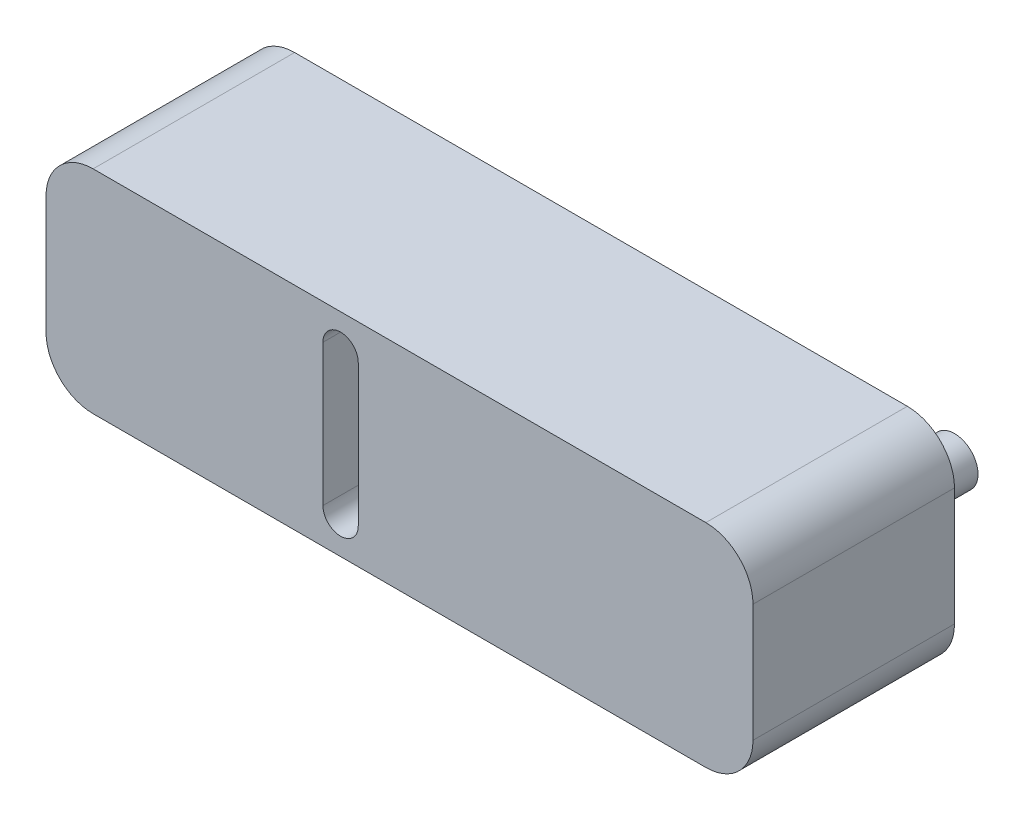
from build123d import *

# Parameters (mm, degrees)
SKETCH1_W           = 76.2
SKETCH1_H           = 22.86
BOSS_EXTRUDE1_DEPTH = 21.717
CUT_EXTRUDE3_REACH  = 23.717
FILLET1_R           = 5.08
SKETCH3_R           = 2.54
BOSS_EXTRUDE2_DEPTH = 8.89


with BuildPart() as part:
    # Sketch1 → Boss-Extrude1 (new body)
    with BuildSketch(Plane.XY):
        Rectangle(SKETCH1_W, SKETCH1_H)
    extrude(amount=-BOSS_EXTRUDE1_DEPTH)

    # Sketch2 → Cut-Extrude3 (cut, up to next)
    with BuildSketch(Plane.XY, mode=Mode.PRIVATE) as cut_extrude3_sk1:
        with BuildLine():
            Line((-8.255, -7.62), (-8.255, 7.62))
            ThreePointArc((-8.255, 7.62), (-6.35, 9.525), (-4.445, 7.62))
            Line((-4.445, 7.62), (-4.445, -7.62))
            ThreePointArc((-4.445, -7.62), (-6.35, -9.525), (-8.255, -7.62))
        make_face()
    cut_extrude3_tool1 = extrude(cut_extrude3_sk1.sketch, amount=-CUT_EXTRUDE3_REACH, mode=Mode.PRIVATE) & part.part
    add(cut_extrude3_tool1.solids().sort_by_distance((-6.35, 0, 0))[0], mode=Mode.SUBTRACT)

    # Fillet1
    fillet1_edges = [part.edges().sort_by_distance(p)[0] for p in [
        (38.1, -11.43, -10.8585),
        (-38.1, -11.43, -10.8585),
        (-38.1, 11.43, -10.8585),
        (38.1, 11.43, -10.8585),
    ]]
    fillet(fillet1_edges, radius=FILLET1_R)

    # Sketch3 → Boss-Extrude2 (add)
    with BuildSketch(Plane(origin=(0, 0, -21.717), x_dir=(-1, 0, 0), z_dir=(0, 0, -1))):
        with Locations((-29.21, 0)):
            Circle(SKETCH3_R)
    extrude(amount=BOSS_EXTRUDE2_DEPTH)


solid = part.part
